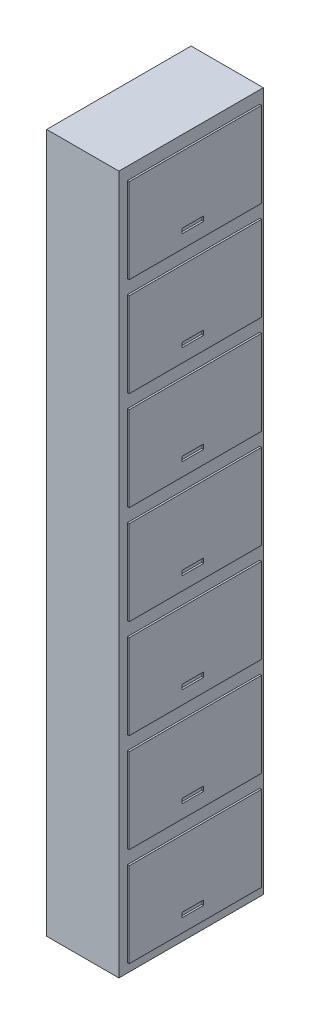
from build123d import *

# Parameters (mm, degrees)
SKETCH1_W           = 400
SKETCH1_H           = 3870
BOSS_EXTRUDE1_DEPTH = 800
SKETCH3_W           = 732.835133331
SKETCH3_H           = 470
SKETCH3_W_2         = 121.072841775
SKETCH3_H_2         = 25.802408902
SKETCH3_H_3         = 25.802408903
BOSS_EXTRUDE3_DEPTH = 10


with BuildPart() as part:
    # Sketch1 → Boss-Extrude1 (new body)
    with BuildSketch(Plane.XY):
        with Locations((63.061970043, 2244.986327315)):
            Rectangle(SKETCH1_W, SKETCH1_H)
    extrude(amount=BOSS_EXTRUDE1_DEPTH)

    # Sketch3 → Boss-Extrude3 (add)
    with BuildSketch(Plane(origin=(263.061970043, 0, 0), x_dir=(0, 0, -1), z_dir=(1, 0, 0))):
        with Locations((-386.417566666, 594.986327315)):
            Rectangle(SKETCH3_W, SKETCH3_H)
        with Locations((-401.128332344, 446.85045415)):
            Rectangle(SKETCH3_W_2, SKETCH3_H_2, mode=Mode.SUBTRACT)
        with Locations((-386.417566666, 1141.758813467)):
            Rectangle(SKETCH3_W, SKETCH3_H)
        with Locations((-401.128332344, 993.622940303)):
            Rectangle(SKETCH3_W_2, SKETCH3_H_3, mode=Mode.SUBTRACT)
        with Locations((-386.417566666, 1688.531299619)):
            Rectangle(SKETCH3_W, SKETCH3_H)
        with Locations((-401.128332344, 1540.395426455)):
            Rectangle(SKETCH3_W_2, SKETCH3_H_3, mode=Mode.SUBTRACT)
        with Locations((-386.417566666, 2235.303785772)):
            Rectangle(SKETCH3_W, SKETCH3_H)
        with Locations((-401.128332344, 2087.167912607)):
            Rectangle(SKETCH3_W_2, SKETCH3_H_3, mode=Mode.SUBTRACT)
        with Locations((-386.417566666, 2782.076271924)):
            Rectangle(SKETCH3_W, SKETCH3_H)
        with Locations((-401.128332344, 2633.940398759)):
            Rectangle(SKETCH3_W_2, SKETCH3_H_3, mode=Mode.SUBTRACT)
        with Locations((-386.417566666, 3328.848758076)):
            Rectangle(SKETCH3_W, SKETCH3_H)
        with Locations((-401.128332344, 3180.712884911)):
            Rectangle(SKETCH3_W_2, SKETCH3_H_2, mode=Mode.SUBTRACT)
        with Locations((-386.417566666, 3875.621244228)):
            Rectangle(SKETCH3_W, SKETCH3_H)
        with Locations((-401.128332344, 3727.485371064)):
            Rectangle(SKETCH3_W_2, SKETCH3_H_3, mode=Mode.SUBTRACT)
    extrude(amount=BOSS_EXTRUDE3_DEPTH)


solid = part.part
